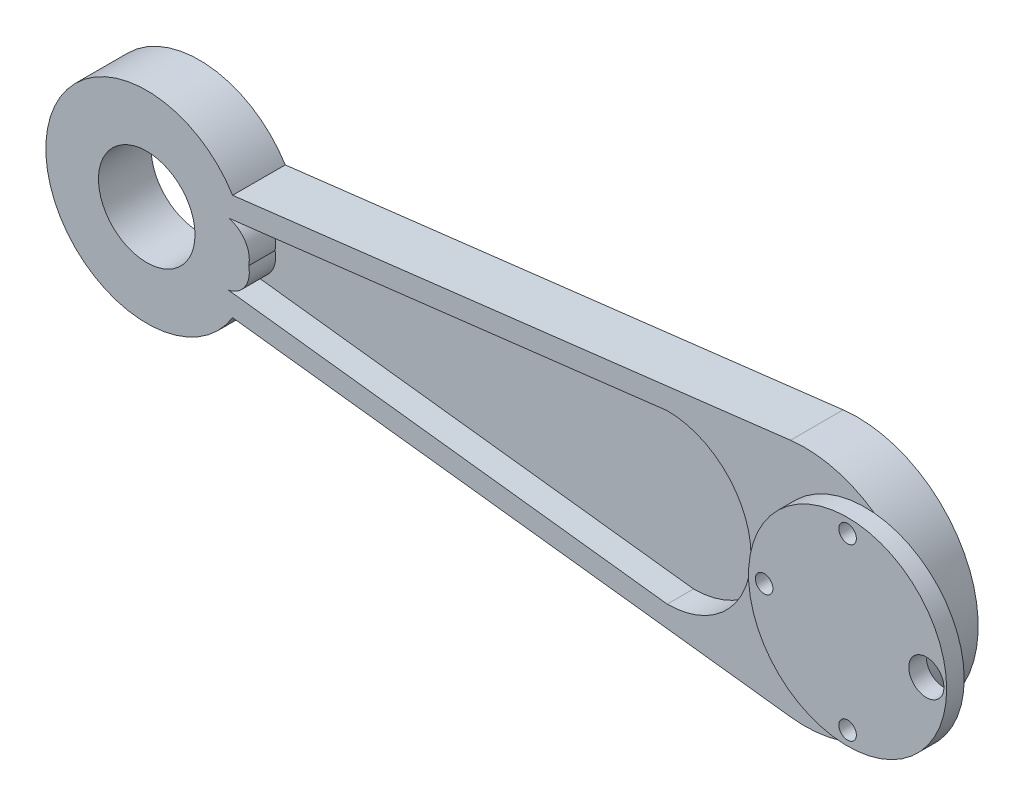
from build123d import *

# Parameters (mm, degrees)
BOSS_EXTRUDE1_DEPTH     = 12
CUT_EXTRUDE1_DEPTH      = 6
SKETCH4_R               = 11
CUT_EXTRUDE2_DEPTH      = 12
SKETCH5_R               = 22.579968686
BOSS_EXTRUDE2_DEPTH     = 4
SKETCH6_R               = 2
CUT_EXTRUDE3_DEPTH      = 16
SKETCH6_3_R             = 2
CUT_EXTRUDE5_DEPTH      = 16
CUT_EXTRUDE6_DEPTH      = 167.374625231
CUT_EXTRUDE6_DEPTH_BACK = 167.374625231
SKETCH7_R               = 4


with BuildPart() as part:
    # Sketch1 → Boss-Extrude1 (new body)
    with BuildSketch(Plane.XY):
        with BuildLine():
            Line((6.425984457, 27.304915127), (-120.730550627, 12.077737738))
            ThreePointArc((-120.730550627, 12.077737738), (-163.304212807, 0), (-120.730550627, -12.077737738))
            Line((-120.730550627, -12.077737738), (6.425984457, -27.304915127))
            ThreePointArc((6.425984457, -27.304915127), (37.195787193, 0), (6.425984457, 27.304915127))
        make_face()
    extrude(amount=BOSS_EXTRUDE1_DEPTH)

    # Sketch3 → Cut-Extrude1 (cut)
    with BuildSketch(Plane.XY.offset(12)):
        with BuildLine():
            Line((-121.670322635, 7.122377923), (-21.678965717, 19.096486278))
            ThreePointArc((-21.678965717, 19.096486278), (-2.5738344, 0), (-21.678965717, -19.096486278))
            Line((-21.678965717, -19.096486278), (-121.670322635, -7.122377923))
            ThreePointArc((-121.670322635, -7.122377923), (-117.889637025, -4.516196787), (-117.059136947, 0))
            ThreePointArc((-117.059136947, 0), (-117.889637025, 4.516196787), (-121.670322635, 7.122377923))
        make_face()
    extrude(amount=-CUT_EXTRUDE1_DEPTH, mode=Mode.SUBTRACT)

    # Sketch4 → Cut-Extrude2 (cut)
    with BuildSketch(Plane.XY.offset(12)):
        with Locations((-140.304212807, 0)):
            Circle(SKETCH4_R)
    extrude(amount=-CUT_EXTRUDE2_DEPTH, mode=Mode.SUBTRACT)

    # Sketch5 → Boss-Extrude2 (add)
    with BuildSketch(Plane.XY.offset(12)):
        with Locations((23.433246409, 0)):
            Circle(SKETCH5_R)
    extrude(amount=BOSS_EXTRUDE2_DEPTH)

    # Sketch6 → Cut-Extrude3 (cut)
    with BuildSketch(Plane.XY.offset(16)):
        with Locations((4.416689948, 0)):
            Circle(SKETCH6_R)
    extrude(amount=-CUT_EXTRUDE3_DEPTH, mode=Mode.SUBTRACT)

    # Sketch6_3 → Cut-Extrude5 (cut)
    with BuildSketch(Plane.XY.offset(16)):
        with Locations((23.433246409, -19.392257926)):
            Circle(SKETCH6_3_R)
        with Locations((42.449802871, 0)):
            Circle(SKETCH6_3_R)
        with Locations((23.433246409, 19.392257926)):
            Circle(SKETCH6_3_R)
    extrude(amount=-CUT_EXTRUDE5_DEPTH, mode=Mode.SUBTRACT)

    # Sketch7 → Cut-Extrude6 (cut, two sides: drawn at the far end of the back side and taken through both)
    with BuildSketch(Plane.XY.offset(16).offset(-CUT_EXTRUDE6_DEPTH_BACK)):
        with Locations((41.377266411, 0)):
            Circle(SKETCH7_R)
    extrude(amount=CUT_EXTRUDE6_DEPTH + CUT_EXTRUDE6_DEPTH_BACK, mode=Mode.SUBTRACT)


solid = part.part
